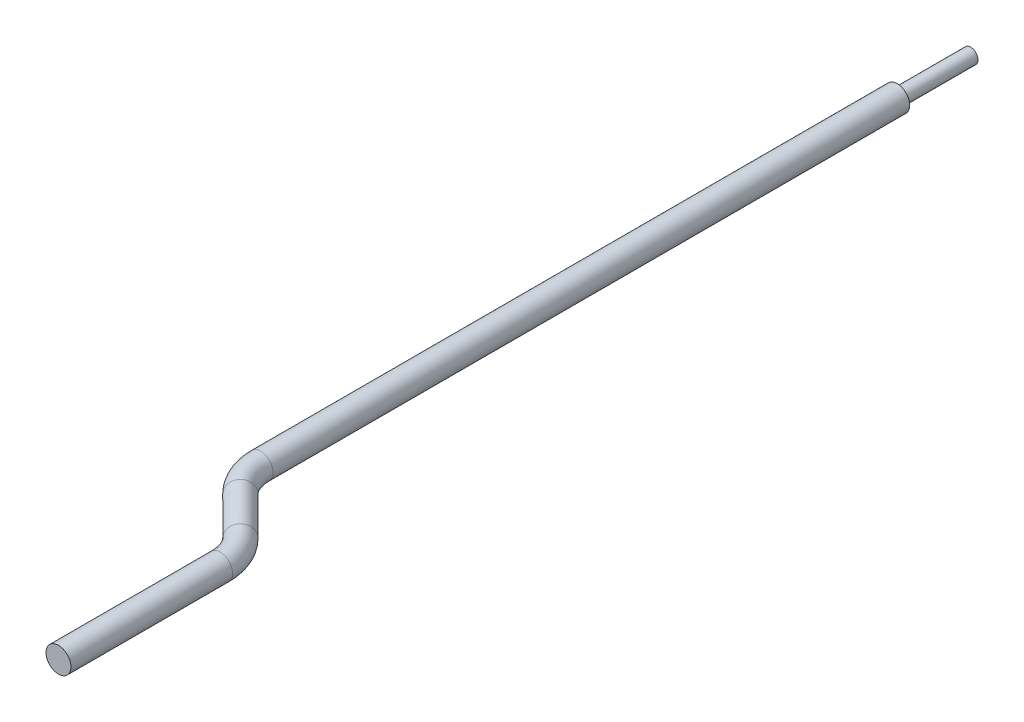
from build123d import *

# Parameters (mm, degrees)
SKETCH1_R           = 0.6477
BOSS_EXTRUDE1_DEPTH = 35.56
SKETCH3_R           = 0.6477
SKETCH4_R           = 0.6477
SKETCH4_R_2         = 0.381
CUT_EXTRUDE2_DEPTH  = 3.81


with BuildPart() as part:
    # Sketch1 → Boss-Extrude1 (new body)
    with BuildSketch(Plane.XY):
        Circle(SKETCH1_R)
    extrude(amount=BOSS_EXTRUDE1_DEPTH)

    # Sweep1: sweep along a path in Sketch2
    with BuildLine(Plane(origin=(0, 0, 0), x_dir=(1, 0, 0), z_dir=(0, 1, 0))) as sweep1_path:
        Line((3.4798, -50.8), (3.4798, -42.414004897))
        ThreePointArc((3.4798, -42.414004897), (3.286454013, -41.441988979), (2.735851224, -40.617953673))
        Line((2.735851224, -40.617953673), (0.743948776, -38.626051224))
        ThreePointArc((0.743948776, -38.626051224), (0.193345987, -37.802015918), (0, -36.83))
        Line((0, -36.83), (0, -35.56))
    # Sketch3 → Sweep1 (sweep)
    with BuildSketch(Plane.XY.offset(35.56)):
        Circle(SKETCH3_R)
    sweep(path=sweep1_path.line)

    # Sketch4 → Cut-Extrude2 (cut)
    with BuildSketch(Plane.XY):
        Circle(SKETCH4_R)
        Circle(SKETCH4_R_2, mode=Mode.SUBTRACT)
    extrude(amount=CUT_EXTRUDE2_DEPTH, mode=Mode.SUBTRACT)


solid = part.part
